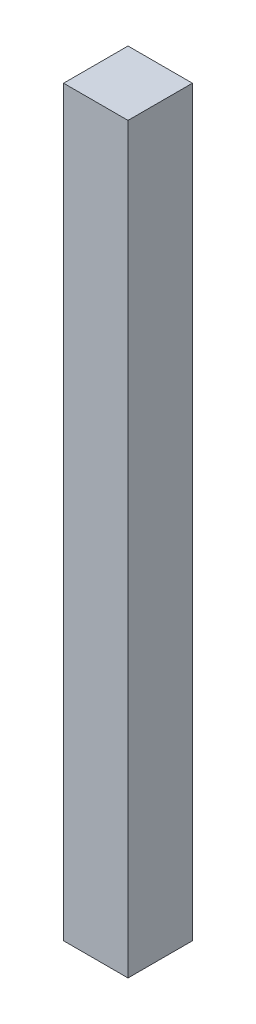
from build123d import *

# Parameters (mm, degrees)
SKETCH1_W           = 25.4
SKETCH1_H           = 25.4
BOSS_EXTRUDE1_DEPTH = 292.85


with BuildPart() as part:
    # Sketch1 → Boss-Extrude1 (new body)
    with BuildSketch(Plane(origin=(0, 0, 0), x_dir=(1, 0, 0), z_dir=(0, 1, 0))):
        Rectangle(SKETCH1_W, SKETCH1_H)
    extrude(amount=BOSS_EXTRUDE1_DEPTH)


solid = part.part
